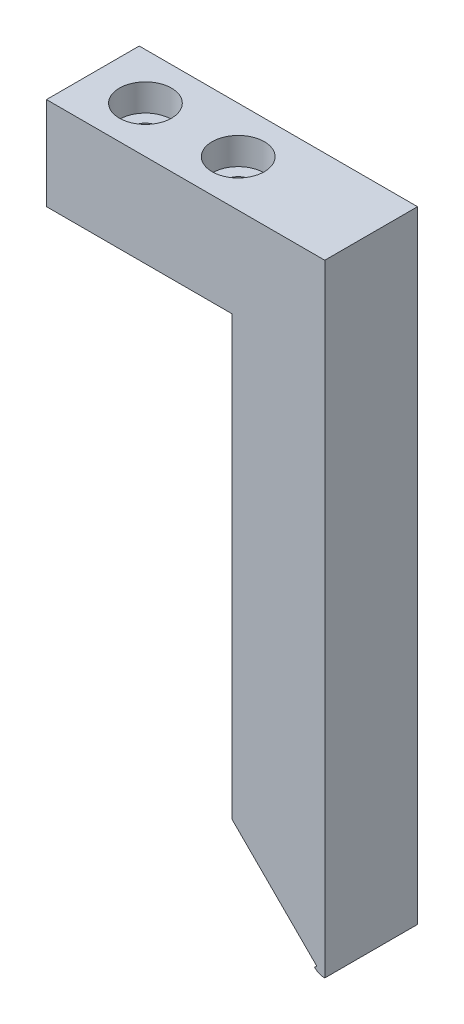
from build123d import *

# Parameters (mm, degrees)
SKETCH1_W                                      = 38.1
SKETCH1_H                                      = 85.1
BOSS_EXTRUDE1_DEPTH                            = 6.35
SKETCH2_W                                      = 25.4
SKETCH2_H                                      = 72.4
CUT_EXTRUDE1_DEPTH                             = 13.7
CBORE_FOR_6_SOCKET_HEAD_CAP_SCREW1_D           = 3.7973
CBORE_FOR_6_SOCKET_HEAD_CAP_SCREW1_CBORE_D     = 7.14502
CBORE_FOR_6_SOCKET_HEAD_CAP_SCREW1_CBORE_DEPTH = 3.7051996
CUT_EXTRUDE2_DEPTH                             = 13.7
CUT_EXTRUDE7_REACH                             = 14.7
F_4_40_TAPPED_HOLE1_D                          = 2.2606
F_4_40_TAPPED_HOLE1_DEPTH                      = 6.18
F_4_40_TAPPED_HOLE1_TIP                        = 0.679152758


with BuildPart() as part:
    # Sketch1 → Boss-Extrude1 (new body, symmetric)
    with BuildSketch(Plane.XY):
        with Locations((19.05, -42.55)):
            Rectangle(SKETCH1_W, SKETCH1_H)
    extrude(amount=BOSS_EXTRUDE1_DEPTH, both=True)

    # Sketch2 → Cut-Extrude1 (cut, through all)
    with BuildSketch(Plane.XY.offset(6.35)):
        with Locations((12.7, -48.9)):
            Rectangle(SKETCH2_W, SKETCH2_H)
    extrude(amount=-CUT_EXTRUDE1_DEPTH, mode=Mode.SUBTRACT)

    # CBORE for #6 Socket Head Cap Screw1 (through all)
    with Locations(Plane(origin=(0, 0, 0), x_dir=(-1, 0, 0), z_dir=(0, 1, 0))):
        with Locations((-7.2, 0), (-19.9, 0)):
            CounterBoreHole(CBORE_FOR_6_SOCKET_HEAD_CAP_SCREW1_D / 2, CBORE_FOR_6_SOCKET_HEAD_CAP_SCREW1_CBORE_D / 2, CBORE_FOR_6_SOCKET_HEAD_CAP_SCREW1_CBORE_DEPTH)

    # Sketch9 → Cut-Extrude2 (cut, through all)
    with BuildSketch(Plane.XY.offset(6.35)):
        with BuildLine():
            Line((25.4, -84.8), (36.685857157, -84.8))
            ThreePointArc((36.685857157, -84.8), (37.012701665, -85.021954446), (37.4, -85.1))
            Line((37.4, -85.1), (38.1, -85.1))
            Line((38.1, -85.1), (38.1, -88.1))
            Line((38.1, -88.1), (25.4, -88.1))
            Line((25.4, -88.1), (25.4, -84.8))
        make_face()
    extrude(amount=-CUT_EXTRUDE2_DEPTH, mode=Mode.SUBTRACT)

    # Sketch24 → Cut-Extrude7 (cut, up to next)
    with BuildSketch(Plane.XY.offset(6.35), mode=Mode.PRIVATE) as cut_extrude7_sk1:
        with BuildLine():
            Line((38.1, -85.1), (38, -85.1))
            ThreePointArc((38, -85.1), (37.296182614, -84.947443375), (36.71869987, -84.517157288))
            Line((36.71869987, -84.517157288), (37.001542582, -84.234314575))
            Line((37.001542582, -84.234314575), (25.4, -72.632771993))
            Line((25.4, -72.632771993), (22.894805483, -72.632771993))
            Line((22.894805483, -72.632771993), (22.894805483, -86.862285397))
            Line((22.894805483, -86.862285397), (38.1, -86.862285397))
            Line((38.1, -86.862285397), (38.1, -85.1))
        make_face()
    cut_extrude7_tool1 = extrude(cut_extrude7_sk1.sketch, amount=-CUT_EXTRUDE7_REACH, mode=Mode.PRIVATE) & part.part
    add(cut_extrude7_tool1.solids().sort_by_distance((28.474666, -81.452091, 6.35))[0], mode=Mode.SUBTRACT)

    # #4-40 Tapped Hole1
    with Locations(Plane(origin=(-19.288878517, -27.943893476, 153.694490084), x_dir=(0.707106781, -0.707106781, 0), z_dir=(-0.707106781, -0.707106781, 0))):
        with Locations((71.626370823, -150.519490084), (71.626370823, -156.869490084)):
            Hole(F_4_40_TAPPED_HOLE1_D / 2, depth=F_4_40_TAPPED_HOLE1_DEPTH)
            with Locations((0, 0, -(F_4_40_TAPPED_HOLE1_DEPTH + F_4_40_TAPPED_HOLE1_TIP / 2))):  # 118° drill point
                Cone(0, F_4_40_TAPPED_HOLE1_D / 2, F_4_40_TAPPED_HOLE1_TIP, mode=Mode.SUBTRACT)


solid = part.part
